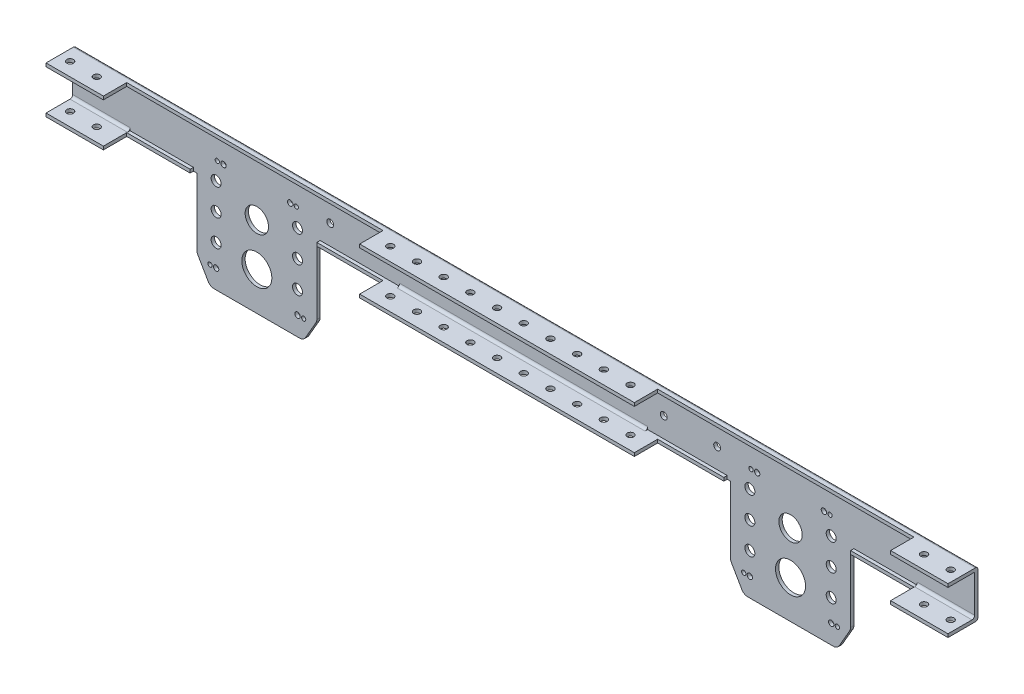
from build123d import *
from build123d.topology import SkipClean

# Parameters (mm, degrees)
SKETCH1_R            = 6.35
BOSS_EXTRUDE1_DEPTH  = 3.175
SKETCH2_W            = 596.9
SKETCH2_H            = 3.175
BOSS_EXTRUDE2_DEPTH  = 25.4
FILLET1_R            = 2.54
SKETCH3_R            = 3.2639
CUT_EXTRUDE1_DEPTH   = 25.4
SKETCH5_R            = 3.2639
CUT_EXTRUDE2_DEPTH   = 25.4
SKETCH6_W            = 31.75
SKETCH6_H            = 44.45
BOSS_EXTRUDE3_DEPTH  = 3.175
SKETCH7_W            = 31.75
SKETCH7_H            = 3.175
SKETCH7_W_2          = 381
BOSS_EXTRUDE4_DEPTH  = 25.4
FILLET2_R            = 2.54
SKETCH8_R            = 3.2639
CUT_EXTRUDE3_DEPTH   = 177.8
SKETCH9_R            = 3.2639
CUT_EXTRUDE5_DEPTH   = 432.308
BOSS_EXTRUDE6_DEPTH  = 66.675
BOSS_EXTRUDE7_START  = 66.675
BOSS_EXTRUDE7_DEPTH  = 66.675
SKETCH12_R           = 6.35
SKETCH12_R_2         = 3.2639
SKETCH12_W           = 256.6289
SKETCH12_H           = 252.715944366
CUT_EXTRUDE8_DEPTH   = 66.675
BOSS_EXTRUDE8_START  = 19.05
BOSS_EXTRUDE8_DEPTH  = 19.05
BOSS_EXTRUDE9_DEPTH  = 19.05
SKETCH16_R           = 3.2639
CUT_EXTRUDE9_DEPTH   = 133.096
SKETCH17_R           = 3.175
CUT_EXTRUDE11_DEPTH  = 5.08
SKETCH18_W           = 256.6289
SKETCH18_H           = 3.175
SKETCH18_W_2         = 838.2
BOSS_EXTRUDE10_DEPTH = 3.175
SKETCH19_W           = 107.950440108
SKETCH19_H           = 6.388661832
SKETCH19_W_2         = 107.95
SKETCH19_H_2         = 3.175
CUT_EXTRUDE12_DEPTH  = 3.175
SKETCH20_W           = 555.272296498
SKETCH20_H           = 244.428342312
SKETCH20_R           = 3.2639
SKETCH20_R_2         = 6.35
SKETCH20_R_3         = 3.175
CUT_EXTRUDE13_DEPTH  = 277.622
BOSS_EXTRUDE11_START = -3.175
SKETCH21_R           = 6.35
BOSS_EXTRUDE11_DEPTH = 3.175
SKETCH22_W           = 47.625
SKETCH22_H           = 22.225
SKETCH22_W_2         = 236.0422
BOSS_EXTRUDE12_DEPTH = 3.175
SKETCH23_W           = 47.625
SKETCH23_H           = 22.225
SKETCH23_W_2         = 236.0422
BOSS_EXTRUDE14_DEPTH = 3.175
BOSS_EXTRUDE15_DEPTH = 12.7
BOSS_EXTRUDE16_START = 12.7
BOSS_EXTRUDE16_DEPTH = 12.7
SKETCH27_R           = 3.175
CUT_EXTRUDE15_DEPTH  = 76.2
SKETCH28_W           = 22.225
SKETCH28_H           = 3.175
BOSS_EXTRUDE17_DEPTH = 12.7
SKETCH29_W           = 22.225
SKETCH29_H           = 3.175
BOSS_EXTRUDE18_DEPTH = 12.7
SKETCH30_R           = 6.35
SKETCH30_R_2         = 5.185373
SKETCH30_R_3         = 5.538595338
BOSS_EXTRUDE19_DEPTH = 3.175
SKETCH31_R           = 14.2875
SKETCH31_R_2         = 11.1125
SKETCH31_R_3         = 4.7625
SKETCH31_R_4         = 2.54
SKETCH31_R_5         = 2.032
CUT_EXTRUDE17_DEPTH  = 3.175
BOSS_EXTRUDE21_DEPTH = 3.175
FILLET4_R            = 6.35
SKETCH34_W           = 94.166192965
SKETCH34_H           = 14.648074461
BOSS_EXTRUDE22_DEPTH = 3.175
SKETCH35_R           = 2.54
SKETCH35_R_2         = 2.032
CUT_EXTRUDE19_DEPTH  = 3.175
SKETCH36_W           = 101.173518356
SKETCH36_H           = 13.169600398
BOSS_EXTRUDE24_DEPTH = 3.175
SKETCH37_W           = 9.525
SKETCH37_H           = 3.175
SKETCH37_W_2         = 3.175
CUT_EXTRUDE20_DEPTH  = 3.175
CUT_EXTRUDE21_START  = -3.175
CUT_EXTRUDE21_DEPTH  = 3.175
CUT_EXTRUDE22_DEPTH  = 3.175
CUT_EXTRUDE23_DEPTH  = 2.54
CUT_EXTRUDE24_START  = -2.54
CUT_EXTRUDE24_DEPTH  = 2.54


with BuildPart() as part:
    # Sketch1 → Boss-Extrude1 (new body)
    with BuildSketch(Plane.XY):
        with BuildLine():
            Line((50.8, 0), (50.8, 25.4))
            ThreePointArc((50.8, 25.4), (52.659871939, 29.890128061), (57.15, 31.75))
            Line((57.15, 31.75), (438.15, 31.75))
            ThreePointArc((438.15, 31.75), (442.640128061, 29.890128061), (444.5, 25.4))
            Line((444.5, 25.4), (444.5, 0))
            ThreePointArc((444.5, 0), (495.3, -50.8), (546.1, 0))
            Line((546.1, 0), (546.1, 76.2))
            Line((546.1, 76.2), (-50.8, 76.2))
            Line((-50.8, 76.2), (-50.8, 0))
            ThreePointArc((-50.8, 0), (0, -50.8), (50.8, 0))
        make_face()
        Circle(SKETCH1_R, mode=Mode.SUBTRACT)
        with Locations((495.3, 0)):
            Circle(SKETCH1_R, mode=Mode.SUBTRACT)
    extrude(amount=BOSS_EXTRUDE1_DEPTH)

    # Sketch2 → Boss-Extrude2 (add)
    with BuildSketch(Plane.XY.offset(3.175)):
        with Locations((247.65, 74.6125)):
            Rectangle(SKETCH2_W, SKETCH2_H)
    extrude(amount=BOSS_EXTRUDE2_DEPTH)

    # Fillet1
    fillet1_edges = [part.edges().sort_by_distance(p)[0] for p in [
        (247.65, 73.025, 3.175),
        (247.65, 76.2, 0),
    ]]
    fillet(fillet1_edges, radius=FILLET1_R)

    # Sketch3 → Cut-Extrude1 (cut)
    with BuildSketch(Plane(origin=(0, 76.2, 0), x_dir=(1, 0, 0), z_dir=(0, 1, 0))):
        with Locations((527.05, -15.5575)):
            Circle(SKETCH3_R)
        with Locations((501.65, -15.5575)):
            Circle(SKETCH3_R)
        with Locations((476.25, -15.5575)):
            Circle(SKETCH3_R)
        with Locations((450.85, -15.5575)):
            Circle(SKETCH3_R)
        with Locations((425.45, -15.5575)):
            Circle(SKETCH3_R)
        with Locations((400.05, -15.5575)):
            Circle(SKETCH3_R)
        with Locations((374.65, -15.5575)):
            Circle(SKETCH3_R)
        with Locations((349.25, -15.5575)):
            Circle(SKETCH3_R)
        with Locations((323.85, -15.5575)):
            Circle(SKETCH3_R)
        with Locations((298.45, -15.5575)):
            Circle(SKETCH3_R)
        with Locations((273.05, -15.5575)):
            Circle(SKETCH3_R)
        with Locations((247.65, -15.5575)):
            Circle(SKETCH3_R)
        with Locations((222.25, -15.5575)):
            Circle(SKETCH3_R)
        with Locations((196.85, -15.5575)):
            Circle(SKETCH3_R)
        with Locations((171.45, -15.5575)):
            Circle(SKETCH3_R)
        with Locations((146.05, -15.5575)):
            Circle(SKETCH3_R)
        with Locations((120.65, -15.5575)):
            Circle(SKETCH3_R)
        with Locations((95.25, -15.5575)):
            Circle(SKETCH3_R)
        with Locations((69.85, -15.5575)):
            Circle(SKETCH3_R)
        with Locations((44.45, -15.5575)):
            Circle(SKETCH3_R)
        with Locations((19.05, -15.5575)):
            Circle(SKETCH3_R)
        with Locations((-6.35, -15.5575)):
            Circle(SKETCH3_R)
        with Locations((-31.75, -15.5575)):
            Circle(SKETCH3_R)
    extrude(amount=-CUT_EXTRUDE1_DEPTH, mode=Mode.SUBTRACT)

    # Sketch5 → Cut-Extrude2 (cut)
    with BuildSketch(Plane(origin=(0, 0, 0), x_dir=(-1, 0, 0), z_dir=(0, 0, -1))):
        with Locations((-425.45, 53.975)):
            Circle(SKETCH5_R)
        with Locations((-374.65, 53.975)):
            Circle(SKETCH5_R)
        with Locations((-323.85, 53.975)):
            Circle(SKETCH5_R)
        with Locations((-273.05, 53.975)):
            Circle(SKETCH5_R)
        with Locations((-222.25, 53.975)):
            Circle(SKETCH5_R)
        with Locations((-171.45, 53.975)):
            Circle(SKETCH5_R)
        with Locations((-120.65, 53.975)):
            Circle(SKETCH5_R)
        with Locations((-69.85, 53.975)):
            Circle(SKETCH5_R)
    extrude(amount=-CUT_EXTRUDE2_DEPTH, mode=Mode.SUBTRACT)

    # Sketch6 → Boss-Extrude3 (add)
    with BuildSketch(Plane.XY.offset(3.175)):
        with Locations((-66.675, 53.975)):
            Rectangle(SKETCH6_W, SKETCH6_H)
        with Locations((561.975, 53.975)):
            Rectangle(SKETCH6_W, SKETCH6_H)
    extrude(amount=-BOSS_EXTRUDE3_DEPTH)

    # Sketch7 → Boss-Extrude4 (add)
    with BuildSketch(Plane.XY.offset(3.175)):
        with Locations((-66.675, 74.6125)):
            Rectangle(SKETCH7_W, SKETCH7_H)
        with Locations((-66.675, 33.3375)):
            Rectangle(SKETCH7_W, SKETCH7_H)
        with Locations((561.975, 74.6125)):
            Rectangle(SKETCH7_W, SKETCH7_H)
        with Locations((561.975, 33.3375)):
            Rectangle(SKETCH7_W, SKETCH7_H)
        with Locations((247.65, 33.3375)):
            Rectangle(SKETCH7_W_2, SKETCH7_H)
    extrude(amount=BOSS_EXTRUDE4_DEPTH)

    # Fillet2
    fillet2_edges = [part.edges().sort_by_distance(p)[0] for p in [
        (-50.8, 15.875, 0),
        (0, -50.8, 0),
        (50.8, 12.7, 0),
        (52.659871939, 29.890128061, 0),
        (546.1, 15.875, 0),
        (495.3, -50.8, 0),
        (444.5, 12.7, 0),
        (442.640128061, 29.890128061, 0),
        (-66.675, 34.925, 3.175),
        (-66.675, 31.75, 0),
        (247.65, 31.75, 0),
        (247.65, 34.925, 3.175),
        (561.975, 34.925, 3.175),
        (561.975, 31.75, 0),
        (561.975, 76.2, 0),
        (-66.675, 76.2, 0),
    ]]
    fillet(fillet2_edges, radius=FILLET2_R)

    # Sketch8 → Cut-Extrude3 (cut)
    with BuildSketch(Plane(origin=(0, 76.2, 0), x_dir=(1, 0, 0), z_dir=(0, 1, 0))):
        with Locations((-31.75, -15.5575)):
            Circle(SKETCH8_R)
        with Locations((-57.15, -15.5575)):
            Circle(SKETCH8_R)
        with Locations((-6.35, -15.5575)):
            Circle(SKETCH8_R)
        with Locations((19.05, -15.5575)):
            Circle(SKETCH8_R)
        with Locations((44.45, -15.5575)):
            Circle(SKETCH8_R)
        with Locations((69.85, -15.5575)):
            Circle(SKETCH8_R)
        with Locations((95.25, -15.5575)):
            Circle(SKETCH8_R)
        with Locations((120.65, -15.5575)):
            Circle(SKETCH8_R)
        with Locations((146.05, -15.5575)):
            Circle(SKETCH8_R)
        with Locations((171.45, -15.5575)):
            Circle(SKETCH8_R)
        with Locations((196.85, -15.5575)):
            Circle(SKETCH8_R)
        with Locations((222.25, -15.5575)):
            Circle(SKETCH8_R)
        with Locations((247.65, -15.5575)):
            Circle(SKETCH8_R)
        with Locations((273.05, -15.5575)):
            Circle(SKETCH8_R)
        with Locations((298.45, -15.5575)):
            Circle(SKETCH8_R)
        with Locations((323.85, -15.5575)):
            Circle(SKETCH8_R)
        with Locations((349.25, -15.5575)):
            Circle(SKETCH8_R)
        with Locations((374.65, -15.5575)):
            Circle(SKETCH8_R)
        with Locations((400.05, -15.5575)):
            Circle(SKETCH8_R)
        with Locations((425.45, -15.5575)):
            Circle(SKETCH8_R)
        with Locations((450.85, -15.5575)):
            Circle(SKETCH8_R)
        with Locations((476.25, -15.5575)):
            Circle(SKETCH8_R)
        with Locations((501.65, -15.5575)):
            Circle(SKETCH8_R)
        with Locations((527.05, -15.5575)):
            Circle(SKETCH8_R)
        with Locations((552.45, -15.5575)):
            Circle(SKETCH8_R)
    extrude(amount=-CUT_EXTRUDE3_DEPTH, mode=Mode.SUBTRACT)

    # Sketch9 → Cut-Extrude5 (cut)
    with BuildSketch(Plane(origin=(0, 76.2, 0), x_dir=(1, 0, 0), z_dir=(0, 1, 0))):
        with BuildLine():
            Line((298.45, -18.8214), (298.45, -28.575))
            Line((298.45, -28.575), (746.392900795, -28.575))
            Line((746.392900795, -28.575), (746.392900795, 89.004110939))
            Line((746.392900795, 89.004110939), (298.45, 89.004110939))
            Line((298.45, 89.004110939), (298.45, -12.2936))
            ThreePointArc((298.45, -12.2936), (301.7139, -15.5575), (298.45, -18.8214))
        make_face()
        with Locations((323.85, -15.5575)):
            Circle(SKETCH9_R, mode=Mode.SUBTRACT)
        with Locations((349.25, -15.5575)):
            Circle(SKETCH9_R, mode=Mode.SUBTRACT)
        with Locations((374.65, -15.5575)):
            Circle(SKETCH9_R, mode=Mode.SUBTRACT)
        with Locations((400.05, -15.5575)):
            Circle(SKETCH9_R, mode=Mode.SUBTRACT)
        with Locations((425.45, -15.5575)):
            Circle(SKETCH9_R, mode=Mode.SUBTRACT)
        with Locations((450.85, -15.5575)):
            Circle(SKETCH9_R, mode=Mode.SUBTRACT)
        with Locations((476.25, -15.5575)):
            Circle(SKETCH9_R, mode=Mode.SUBTRACT)
        with Locations((501.65, -15.5575)):
            Circle(SKETCH9_R, mode=Mode.SUBTRACT)
        with Locations((527.05, -15.5575)):
            Circle(SKETCH9_R, mode=Mode.SUBTRACT)
        with Locations((552.45, -15.5575)):
            Circle(SKETCH9_R, mode=Mode.SUBTRACT)
    extrude(amount=-CUT_EXTRUDE5_DEPTH, mode=Mode.SUBTRACT)

    # Mirror4: part across plane


with BuildPart() as part_1:
    with SkipClean():  # the faces are left unmerged after this step: merging them gives an invalid solid
        add(part.part)
        add(part.part.mirror(Plane(origin=(298.45, -356.108, 0), x_dir=(0, 0, 1), z_dir=(1, 0, 0))))

    # Sketch10 → Boss-Extrude6 (add)
    with SkipClean():  # the faces are left unmerged after this step: merging them gives an invalid solid
        with BuildSketch(Plane.ZY.offset(82.55)):
            with BuildLine():
                Line((0, 73.66), (0, 34.29))
                ThreePointArc((0, 34.29), (0.743948776, 32.493948776), (2.54, 31.75))
                Line((2.54, 31.75), (28.575, 31.75))
                Line((28.575, 31.75), (28.575, 34.925))
                Line((28.575, 34.925), (5.715, 34.925))
                ThreePointArc((5.715, 34.925), (3.918948776, 35.668948776), (3.175, 37.465))
                Line((3.175, 37.465), (3.175, 73.025))
                Line((3.175, 73.025), (28.575, 73.025))
                Line((28.575, 73.025), (28.575, 76.2))
                Line((28.575, 76.2), (2.54, 76.2))
                ThreePointArc((2.54, 76.2), (0.743948776, 75.456051224), (0, 73.66))
            make_face()
        extrude(amount=BOSS_EXTRUDE6_DEPTH)

    # Sketch11 → Boss-Extrude7 (add)
    with SkipClean():  # the faces are left unmerged after this step: merging them gives an invalid solid
        with BuildSketch(Plane(origin=(679.45, 0, 0), x_dir=(0, 0, -1), z_dir=(1, 0, 0)).offset(BOSS_EXTRUDE7_START)):
            with BuildLine():
                Line((0, 34.29), (0, 73.66))
                ThreePointArc((0, 73.66), (-0.743948776, 75.456051224), (-2.54, 76.2))
                Line((-2.54, 76.2), (-28.575, 76.2))
                Line((-28.575, 76.2), (-28.575, 73.025))
                Line((-28.575, 73.025), (-3.175, 73.025))
                Line((-3.175, 73.025), (-3.175, 37.465))
                ThreePointArc((-3.175, 37.465), (-3.918948776, 35.668948776), (-5.715, 34.925))
                Line((-5.715, 34.925), (-28.575, 34.925))
                Line((-28.575, 34.925), (-28.575, 31.75))
                Line((-28.575, 31.75), (-2.54, 31.75))
                ThreePointArc((-2.54, 31.75), (-0.743948776, 32.493948776), (0, 34.29))
            make_face()
        extrude(amount=-BOSS_EXTRUDE7_DEPTH)

    # Sketch12 → Cut-Extrude8 (cut)
    # profile 1 of 2: a face of its own
    with SkipClean():  # the faces are left unmerged after this step: merging them gives an invalid solid
        with BuildSketch(Plane.XY.offset(3.175)):
            with BuildLine():
                Line((135.9789, 114.3), (-120.65, 114.3))
                Line((-120.65, 114.3), (-120.65, -7.986269461))
                Line((-120.65, -7.986269461), (-114.3, -7.986269461))
                Line((-114.3, -7.986269461), (-114.3, 0))
                ThreePointArc((-114.3, 0), (0, -114.3), (114.3, 0))
                Line((114.3, 0), (114.3, -15.458780647))
                Line((114.3, -15.458780647), (135.9789, -15.458780647))
                Line((135.9789, -15.458780647), (135.9789, 114.3))
            make_face()
            Circle(SKETCH12_R, mode=Mode.SUBTRACT)
            with Locations((69.85, 53.975)):
                Circle(SKETCH12_R_2, mode=Mode.SUBTRACT)
            with Locations((120.65, 53.975)):
                Circle(SKETCH12_R_2, mode=Mode.SUBTRACT)
        # profile 2 of 2: a face of its own
        with BuildSketch(Plane.XY.offset(3.175)):
            with Locations((589.23555, 8.748218221)):
                Rectangle(SKETCH12_W, SKETCH12_H)
            with Locations((596.9, 0)):
                Circle(SKETCH12_R, mode=Mode.SUBTRACT)
            with Locations((476.25, 53.975)):
                Circle(SKETCH12_R_2, mode=Mode.SUBTRACT)
            with Locations((527.05, 53.975)):
                Circle(SKETCH12_R_2, mode=Mode.SUBTRACT)
        extrude(amount=CUT_EXTRUDE8_DEPTH, mode=Mode.SUBTRACT)

    # Sketch14 → Boss-Extrude8 (add)
    with SkipClean():  # the faces are left unmerged after this step: merging them gives an invalid solid
        with BuildSketch(Plane(origin=(746.125, 0, 0), x_dir=(0, 0, -1), z_dir=(1, 0, 0)).offset(BOSS_EXTRUDE8_START)):
            with BuildLine():
                Line((0, 34.29), (0, 73.66))
                ThreePointArc((0, 73.66), (-0.743948776, 75.456051224), (-2.54, 76.2))
                Line((-2.54, 76.2), (-28.575, 76.2))
                Line((-28.575, 76.2), (-28.575, 73.025))
                Line((-28.575, 73.025), (-3.175, 73.025))
                Line((-3.175, 73.025), (-3.175, 37.465))
                ThreePointArc((-3.175, 37.465), (-3.918948776, 35.668948776), (-5.715, 34.925))
                Line((-5.715, 34.925), (-28.575, 34.925))
                Line((-28.575, 34.925), (-28.575, 31.75))
                Line((-28.575, 31.75), (-2.54, 31.75))
                ThreePointArc((-2.54, 31.75), (-0.743948776, 32.493948776), (0, 34.29))
            make_face()
        extrude(amount=-BOSS_EXTRUDE8_DEPTH)

    # Sketch15 → Boss-Extrude9 (add)
    with SkipClean():  # the faces are left unmerged after this step: merging them gives an invalid solid
        with BuildSketch(Plane.ZY.offset(149.225)):
            with BuildLine():
                Line((0, 73.66), (0, 34.29))
                ThreePointArc((0, 34.29), (0.743948776, 32.493948776), (2.54, 31.75))
                Line((2.54, 31.75), (28.575, 31.75))
                Line((28.575, 31.75), (28.575, 34.925))
                Line((28.575, 34.925), (5.715, 34.925))
                ThreePointArc((5.715, 34.925), (3.918948776, 35.668948776), (3.175, 37.465))
                Line((3.175, 37.465), (3.175, 73.025))
                Line((3.175, 73.025), (28.575, 73.025))
                Line((28.575, 73.025), (28.575, 76.2))
                Line((28.575, 76.2), (2.54, 76.2))
                ThreePointArc((2.54, 76.2), (0.743948776, 75.456051224), (0, 73.66))
            make_face()
        extrude(amount=BOSS_EXTRUDE9_DEPTH)

    # Sketch16 → Cut-Extrude9 (cut)
    with SkipClean():  # the faces are left unmerged after this step: merging them gives an invalid solid
        with BuildSketch(Plane(origin=(0, 76.2, 0), x_dir=(1, 0, 0), z_dir=(0, 1, 0))):
            with Locations((146.05, -15.5575)):
                Circle(SKETCH16_R)
            with Locations((171.45, -15.5575)):
                Circle(SKETCH16_R)
            with Locations((196.85, -15.5575)):
                Circle(SKETCH16_R)
            with Locations((222.25, -15.5575)):
                Circle(SKETCH16_R)
            with Locations((247.65, -15.5575)):
                Circle(SKETCH16_R)
            with Locations((273.05, -15.5575)):
                Circle(SKETCH16_R)
            with Locations((298.45, -15.5575)):
                Circle(SKETCH16_R)
            with Locations((323.85, -15.5575)):
                Circle(SKETCH16_R)
            with Locations((349.25, -15.5575)):
                Circle(SKETCH16_R)
            with Locations((374.65, -15.5575)):
                Circle(SKETCH16_R)
            with Locations((400.05, -15.5575)):
                Circle(SKETCH16_R)
            with Locations((425.45, -15.5575)):
                Circle(SKETCH16_R)
            with Locations((450.85, -15.5575)):
                Circle(SKETCH16_R)
            with Locations((476.25, -15.5575)):
                Circle(SKETCH16_R)
            with Locations((501.65, -15.5575)):
                Circle(SKETCH16_R)
            with Locations((527.05, -15.5575)):
                Circle(SKETCH16_R)
            with Locations((552.45, -15.5575)):
                Circle(SKETCH16_R)
            with Locations((577.85, -15.5575)):
                Circle(SKETCH16_R)
            with Locations((603.25, -15.5575)):
                Circle(SKETCH16_R)
            with Locations((628.65, -15.5575)):
                Circle(SKETCH16_R)
            with Locations((654.05, -15.5575)):
                Circle(SKETCH16_R)
            with Locations((679.45, -15.5575)):
                Circle(SKETCH16_R)
            with Locations((704.85, -15.5575)):
                Circle(SKETCH16_R)
            with Locations((730.25, -15.5575)):
                Circle(SKETCH16_R)
            with Locations((755.65, -15.5575)):
                Circle(SKETCH16_R)
            with Locations((120.65, -15.5575)):
                Circle(SKETCH16_R)
            with Locations((95.25, -15.5575)):
                Circle(SKETCH16_R)
            with Locations((69.85, -15.5575)):
                Circle(SKETCH16_R)
            with Locations((44.45, -15.5575)):
                Circle(SKETCH16_R)
            with Locations((19.05, -15.5575)):
                Circle(SKETCH16_R)
            with Locations((-6.35, -15.5575)):
                Circle(SKETCH16_R)
            with Locations((-31.75, -15.5575)):
                Circle(SKETCH16_R)
            with Locations((-57.15, -15.5575)):
                Circle(SKETCH16_R)
            with Locations((-82.55, -15.5575)):
                Circle(SKETCH16_R)
            with Locations((-107.95, -15.5575)):
                Circle(SKETCH16_R)
            with Locations((-133.35, -15.5575)):
                Circle(SKETCH16_R)
            with Locations((-158.75, -15.5575)):
                Circle(SKETCH16_R)
        extrude(amount=-CUT_EXTRUDE9_DEPTH, mode=Mode.SUBTRACT)

    # Sketch17 → Cut-Extrude11 (cut)
    with SkipClean():  # the faces are left unmerged after this step: merging them gives an invalid solid
        with BuildSketch(Plane(origin=(0, 0, 0), x_dir=(-1, 0, 0), z_dir=(0, 0, -1))):
            with Locations((0, 63.5)):
                Circle(SKETCH17_R)
            with Locations((-596.9, 63.5)):
                Circle(SKETCH17_R)
        extrude(amount=-CUT_EXTRUDE11_DEPTH, mode=Mode.SUBTRACT)

    # Sketch18 → Boss-Extrude10 (add)
    with SkipClean():  # the faces are left unmerged after this step: merging them gives an invalid solid
        with BuildSketch(Plane.XY.offset(3.175)):
            with Locations((7.66445, 74.6125)):
                Rectangle(SKETCH18_W, SKETCH18_H)
            with Locations((589.23555, 74.6125)):
                Rectangle(SKETCH18_W, SKETCH18_H)
            with Locations((298.45, 33.3375)):
                Rectangle(SKETCH18_W_2, SKETCH18_H)
        extrude(amount=BOSS_EXTRUDE10_DEPTH)

    # Sketch19 → Cut-Extrude12 (cut)
    with SkipClean():  # the faces are left unmerged after this step: merging them gives an invalid solid
        with BuildSketch(Plane.XY.offset(3.175)):
            with Locations((3.175220054, 34.944330916)):
                Rectangle(SKETCH19_W, SKETCH19_H)
            with Locations((593.725, 33.3375)):
                Rectangle(SKETCH19_W_2, SKETCH19_H_2)
        extrude(amount=CUT_EXTRUDE12_DEPTH, mode=Mode.SUBTRACT)

    # Sketch20 → Cut-Extrude13 (cut)
    with BuildSketch(Plane(origin=(0, 0, 0), x_dir=(-1, 0, 0), z_dir=(0, 0, -1))):
        with Locations((-65.263851751, 61.916295681)):
            Rectangle(SKETCH20_W, SKETCH20_H)
        with Locations((-323.85, 53.975)):
            Circle(SKETCH20_R, mode=Mode.SUBTRACT)
        with Locations((-273.05, 53.975)):
            Circle(SKETCH20_R, mode=Mode.SUBTRACT)
        with Locations((-222.25, 53.975)):
            Circle(SKETCH20_R, mode=Mode.SUBTRACT)
        with Locations((-171.45, 53.975)):
            Circle(SKETCH20_R, mode=Mode.SUBTRACT)
        with Locations((-120.65, 53.975)):
            Circle(SKETCH20_R, mode=Mode.SUBTRACT)
        with Locations((-69.85, 53.975)):
            Circle(SKETCH20_R, mode=Mode.SUBTRACT)
        Circle(SKETCH20_R_2, mode=Mode.SUBTRACT)
        with Locations((0, 63.5)):
            Circle(SKETCH20_R_3, mode=Mode.SUBTRACT)
    extrude(amount=-CUT_EXTRUDE13_DEPTH, mode=Mode.SUBTRACT)

    # Sketch21 → Boss-Extrude11 (add)
    with BuildSketch(Plane.XY.offset(3.175).offset(BOSS_EXTRUDE11_START)):
        with BuildLine():
            Line((546.1, 0), (546.1, 25.4))
            ThreePointArc((546.1, 25.4), (544.240128061, 29.890128061), (539.75, 31.75))
            Line((539.75, 31.75), (539.75, 34.925))
            Line((539.75, 34.925), (647.7, 34.925))
            Line((647.7, 34.925), (647.7, 31.75))
            Line((647.7, 31.75), (647.7, 0))
            ThreePointArc((647.7, 0), (596.9, -50.8), (546.1, 0))
        make_face()
        with Locations((596.9, 0)):
            Circle(SKETCH21_R, mode=Mode.SUBTRACT)
    extrude(amount=BOSS_EXTRUDE11_DEPTH)

    # Mirror5: part across plane


with BuildPart() as part_2:
    add(part_1.part)
    add(part_1.part.mirror(Plane(origin=(342.9, 0, 277.622), x_dir=(0, 0, 1), z_dir=(1, 0, 0))))

    # Sketch22 → Boss-Extrude12 (add)
    with BuildSketch(Plane(origin=(0, 76.2, 0), x_dir=(1, 0, 0), z_dir=(0, 1, 0))):
        with Locations((741.3625, -17.4625)):
            Rectangle(SKETCH22_W, SKETCH22_H)
        with Locations((342.9, -17.4625)):
            Rectangle(SKETCH22_W_2, SKETCH22_H)
        with Locations((-55.5625, -17.4625)):
            Rectangle(SKETCH22_W, SKETCH22_H)
    extrude(amount=-BOSS_EXTRUDE12_DEPTH)

    # Sketch23 → Boss-Extrude14 (add)
    with BuildSketch(Plane.XZ.offset(-31.75)):
        with Locations((-55.5625, 17.4625)):
            Rectangle(SKETCH23_W, SKETCH23_H)
        with Locations((342.9, 17.4625)):
            Rectangle(SKETCH23_W_2, SKETCH23_H)
        with Locations((741.3625, 17.4625)):
            Rectangle(SKETCH23_W, SKETCH23_H)
    extrude(amount=-BOSS_EXTRUDE14_DEPTH)

    # Sketch25 → Boss-Extrude15 (add)
    with BuildSketch(Plane.ZY.offset(79.375)):
        with BuildLine():
            Line((2.54, 31.75), (28.575, 31.75))
            Line((28.575, 31.75), (28.575, 34.925))
            Line((28.575, 34.925), (5.715, 34.925))
            ThreePointArc((5.715, 34.925), (3.918948776, 35.668948776), (3.175, 37.465))
            Line((3.175, 37.465), (3.175, 73.025))
            Line((3.175, 73.025), (28.575, 73.025))
            Line((28.575, 73.025), (28.575, 76.2))
            Line((28.575, 76.2), (2.54, 76.2))
            ThreePointArc((2.54, 76.2), (0.743948776, 75.456051224), (0, 73.66))
            Line((0, 73.66), (0, 34.29))
            ThreePointArc((0, 34.29), (0.743948776, 32.493948776), (2.54, 31.75))
        make_face()
    extrude(amount=BOSS_EXTRUDE15_DEPTH)

    # Sketch26 → Boss-Extrude16 (add)
    with BuildSketch(Plane(origin=(765.175, 0, 0), x_dir=(0, 0, -1), z_dir=(1, 0, 0)).offset(BOSS_EXTRUDE16_START)):
        with BuildLine():
            Line((-5.715, 34.925), (-28.575, 34.925))
            Line((-28.575, 34.925), (-28.575, 31.75))
            Line((-28.575, 31.75), (-2.54, 31.75))
            ThreePointArc((-2.54, 31.75), (-0.743948776, 32.493948776), (0, 34.29))
            Line((0, 34.29), (0, 73.66))
            ThreePointArc((0, 73.66), (-0.743948776, 75.456051224), (-2.54, 76.2))
            Line((-2.54, 76.2), (-28.575, 76.2))
            Line((-28.575, 76.2), (-28.575, 73.025))
            Line((-28.575, 73.025), (-3.175, 73.025))
            Line((-3.175, 73.025), (-3.175, 37.465))
            ThreePointArc((-3.175, 37.465), (-3.918948776, 35.668948776), (-5.715, 34.925))
        make_face()
    extrude(amount=-BOSS_EXTRUDE16_DEPTH)

    # Sketch27 → Cut-Extrude15 (cut)
    with BuildSketch(Plane(origin=(0, 76.2, 0), x_dir=(1, 0, 0), z_dir=(0, 1, 0))):
        with Locations((762, -15.788044632)):
            Circle(SKETCH27_R)
        with Locations((736.6, -15.788044632)):
            Circle(SKETCH27_R)
        with Locations((711.2, -15.788044632)):
            Circle(SKETCH27_R)
        with Locations((685.8, -15.788044632)):
            Circle(SKETCH27_R)
        with Locations((660.4, -15.788044632)):
            Circle(SKETCH27_R)
        with Locations((635, -15.788044632)):
            Circle(SKETCH27_R)
        with Locations((609.6, -15.788044632)):
            Circle(SKETCH27_R)
        with Locations((584.2, -15.788044632)):
            Circle(SKETCH27_R)
        with Locations((558.8, -15.788044632)):
            Circle(SKETCH27_R)
        with Locations((533.4, -15.788044632)):
            Circle(SKETCH27_R)
        with Locations((508, -15.788044632)):
            Circle(SKETCH27_R)
        with Locations((482.6, -15.788044632)):
            Circle(SKETCH27_R)
        with Locations((457.2, -15.788044632)):
            Circle(SKETCH27_R)
        with Locations((431.8, -15.788044632)):
            Circle(SKETCH27_R)
        with Locations((406.4, -15.788044632)):
            Circle(SKETCH27_R)
        with Locations((381, -15.788044632)):
            Circle(SKETCH27_R)
        with Locations((355.6, -15.788044632)):
            Circle(SKETCH27_R)
        with Locations((330.2, -15.788044632)):
            Circle(SKETCH27_R)
        with Locations((304.8, -15.788044632)):
            Circle(SKETCH27_R)
        with Locations((279.4, -15.788044632)):
            Circle(SKETCH27_R)
        with Locations((254, -15.788044632)):
            Circle(SKETCH27_R)
        with Locations((228.6, -15.788044632)):
            Circle(SKETCH27_R)
        with Locations((203.2, -15.788044632)):
            Circle(SKETCH27_R)
        with Locations((177.8, -15.788044632)):
            Circle(SKETCH27_R)
        with Locations((152.4, -15.788044632)):
            Circle(SKETCH27_R)
        with Locations((127, -15.788044632)):
            Circle(SKETCH27_R)
        with Locations((101.6, -15.788044632)):
            Circle(SKETCH27_R)
        with Locations((76.2, -15.788044632)):
            Circle(SKETCH27_R)
        with Locations((50.8, -15.788044632)):
            Circle(SKETCH27_R)
        with Locations((25.4, -15.788044632)):
            Circle(SKETCH27_R)
        with Locations((0, -15.788044632)):
            Circle(SKETCH27_R)
        with Locations((-25.4, -15.788044632)):
            Circle(SKETCH27_R)
        with Locations((-50.8, -15.788044632)):
            Circle(SKETCH27_R)
        with Locations((-76.2, -15.788044632)):
            Circle(SKETCH27_R)
    extrude(amount=-CUT_EXTRUDE15_DEPTH, mode=Mode.SUBTRACT)

    # Sketch28 → Boss-Extrude17 (add)
    with BuildSketch(Plane.ZY.offset(-224.8789)):
        with Locations((17.4625, 74.6125)):
            Rectangle(SKETCH28_W, SKETCH28_H)
        with Locations((17.4625, 33.3375)):
            Rectangle(SKETCH28_W, SKETCH28_H)
    extrude(amount=BOSS_EXTRUDE17_DEPTH)

    # Sketch29 → Boss-Extrude18 (add)
    with BuildSketch(Plane(origin=(460.9211, 0, 0), x_dir=(0, 0, -1), z_dir=(1, 0, 0))):
        with Locations((-17.4625, 74.6125)):
            Rectangle(SKETCH29_W, SKETCH29_H)
        with Locations((-17.4625, 33.3375)):
            Rectangle(SKETCH29_W, SKETCH29_H)
    extrude(amount=BOSS_EXTRUDE18_DEPTH)

    # Sketch30 → Boss-Extrude19 (add)
    with BuildSketch(Plane(origin=(0, 0, 0), x_dir=(-1, 0, 0), z_dir=(0, 0, -1))):
        with Locations((-88.9, 0)):
            Circle(SKETCH30_R)
        with Locations((-596.9, 0)):
            Circle(SKETCH30_R)
        with Locations((-596.9, 63.862726265)):
            Circle(SKETCH30_R_2)
        with Locations((-88.9, 63.5)):
            Circle(SKETCH30_R_3)
    extrude(amount=-BOSS_EXTRUDE19_DEPTH)

    # Sketch31 → Cut-Extrude17 (cut)
    with BuildSketch(Plane(origin=(0, 0, 0), x_dir=(-1, 0, 0), z_dir=(0, 0, -1))):
        with Locations((-596.9, -19.05)):
            Circle(SKETCH31_R)
        with Locations((-596.9, 21.6408)):
            Circle(SKETCH31_R_2)
        with Locations((-558.17570279, 9.144)):
            Circle(SKETCH31_R_3)
        with Locations((-558.17570279, 34.544)):
            Circle(SKETCH31_R_3)
        with Locations((-558.17570279, -16.256)):
            Circle(SKETCH31_R_3)
        with Locations((-565.15, 57.205147634)):
            Circle(SKETCH31_R_4)
        with Locations((-559.308, 57.205147634)):
            Circle(SKETCH31_R_5)
        with Locations((-635.62429721, -16.256)):
            Circle(SKETCH31_R_3)
        with Locations((-635.62429721, 9.144)):
            Circle(SKETCH31_R_3)
        with Locations((-634.492, 57.205147634)):
            Circle(SKETCH31_R_5)
        with Locations((-628.65, 57.205147634)):
            Circle(SKETCH31_R_4)
        with Locations((-635.62429721, 34.544)):
            Circle(SKETCH31_R_3)
        with Locations((-50.17570279, -16.256)):
            Circle(SKETCH31_R_3)
        with Locations((-50.17570279, 9.144)):
            Circle(SKETCH31_R_3)
        with Locations((-50.17570279, 34.544)):
            Circle(SKETCH31_R_3)
        with Locations((-51.308, 57.205147634)):
            Circle(SKETCH31_R_5)
        with Locations((-57.15, 57.205147634)):
            Circle(SKETCH31_R_4)
        with Locations((-88.9, 21.6408)):
            Circle(SKETCH31_R_2)
        with Locations((-126.492, 57.205147634)):
            Circle(SKETCH31_R_5)
        with Locations((-120.65, 57.205147634)):
            Circle(SKETCH31_R_4)
        with Locations((-127.62429721, 34.544)):
            Circle(SKETCH31_R_3)
        with Locations((-127.62429721, 9.144)):
            Circle(SKETCH31_R_3)
        with Locations((-127.62429721, -16.256)):
            Circle(SKETCH31_R_3)
        with Locations((-88.9, -19.05)):
            Circle(SKETCH31_R)
    extrude(amount=-CUT_EXTRUDE17_DEPTH, mode=Mode.SUBTRACT)

    # Sketch33 → Boss-Extrude21 (add)
    with BuildSketch(Plane(origin=(0, 0, 0), x_dir=(-1, 0, 0), z_dir=(0, 0, -1))):
        with BuildLine():
            Line((-654.05, -33.374954744), (-641.35, -55.372))
            Line((-641.35, -55.372), (-552.45, -55.372))
            Line((-552.45, -55.372), (-539.75, -33.374954744))
            Line((-539.75, -33.374954744), (-539.75, 31.75))
            ThreePointArc((-539.75, 31.75), (-544.240128061, 29.890128061), (-546.1, 25.4))
            Line((-546.1, 25.4), (-546.1, 0))
            ThreePointArc((-546.1, 0), (-596.9, -50.8), (-647.7, 0))
            Line((-647.7, 0), (-647.7, 34.29))
            Line((-647.7, 34.29), (-654.05, 34.29))
            Line((-654.05, 34.29), (-654.05, -33.374954744))
        make_face()
        with BuildLine():
            Line((-139.7, 0), (-139.7, 25.4))
            ThreePointArc((-139.7, 25.4), (-141.559871939, 29.890128061), (-146.05, 31.75))
            Line((-146.05, 31.75), (-146.05, -33.374954744))
            Line((-146.05, -33.374954744), (-133.35, -55.372))
            Line((-133.35, -55.372), (-44.45, -55.372))
            Line((-44.45, -55.372), (-31.75, -33.374954744))
            Line((-31.75, -33.374954744), (-31.75, 34.29))
            Line((-31.75, 34.29), (-38.1, 34.29))
            Line((-38.1, 34.29), (-38.1, 0))
            ThreePointArc((-38.1, 0), (-88.9, -50.8), (-139.7, 0))
        make_face()
    extrude(amount=-BOSS_EXTRUDE21_DEPTH)

    # Fillet4
    fillet4_edges = [part_2.edges().sort_by_distance(p)[0] for p in [
        (146.05, -33.374954744, 1.5875),
        (133.35, -55.372, 1.5875),
        (44.45, -55.372, 1.5875),
        (31.75, -33.374954744, 1.5875),
        (539.75, -33.374954744, 1.5875),
        (552.45, -55.372, 1.5875),
        (641.35, -55.372, 1.5875),
        (654.05, -33.374954744, 1.5875),
    ]]
    fillet(fillet4_edges, radius=FILLET4_R)

    # Sketch34 → Boss-Extrude22 (add)
    with BuildSketch(Plane.XY.offset(3.175)):
        with Locations((84.981170213, 57.98826549)):
            Rectangle(SKETCH34_W, SKETCH34_H)
    extrude(amount=-BOSS_EXTRUDE22_DEPTH)

    # Sketch35 → Cut-Extrude19 (cut)
    with BuildSketch(Plane.XY.offset(3.175)):
        with Locations((120.65, 51.53152)):
            Circle(SKETCH35_R)
        with Locations((126.492, 51.53152)):
            Circle(SKETCH35_R_2)
        with Locations((127.62429721, -37.36086)):
            Circle(SKETCH35_R)
        with Locations((133.46629721, -37.36086)):
            Circle(SKETCH35_R_2)
        with Locations((44.33370279, -37.36086)):
            Circle(SKETCH35_R_2)
        with Locations((50.17570279, -37.36086)):
            Circle(SKETCH35_R)
        with Locations((51.308, 51.53152)):
            Circle(SKETCH35_R_2)
        with Locations((57.15, 51.53152)):
            Circle(SKETCH35_R)
        with Locations((628.65, 51.53152)):
            Circle(SKETCH35_R)
        with Locations((634.492, 51.53152)):
            Circle(SKETCH35_R_2)
        with Locations((635.62429721, -37.36086)):
            Circle(SKETCH35_R)
        with Locations((641.46629721, -37.36086)):
            Circle(SKETCH35_R_2)
        with Locations((552.33370279, -37.36086)):
            Circle(SKETCH35_R_2)
        with Locations((558.17570279, -37.36086)):
            Circle(SKETCH35_R)
        with Locations((559.308, 51.53152)):
            Circle(SKETCH35_R_2)
        with Locations((565.15, 51.53152)):
            Circle(SKETCH35_R)
    extrude(amount=-CUT_EXTRUDE19_DEPTH, mode=Mode.SUBTRACT)

    # Sketch36 → Boss-Extrude24 (add)
    with BuildSketch(Plane.XY.offset(3.175)):
        with Locations((602.956965064, 61.018078597)):
            Rectangle(SKETCH36_W, SKETCH36_H)
    extrude(amount=-BOSS_EXTRUDE24_DEPTH)

    # Sketch37 → Cut-Extrude20 (cut)
    with BuildSketch(Plane.XY.offset(3.175)):
        with Locations((33.3375, 33.3375)):
            Rectangle(SKETCH37_W, SKETCH37_H)
        with Locations((147.6375, 33.3375)):
            Rectangle(SKETCH37_W_2, SKETCH37_H)
        with Locations((652.4625, 33.3375)):
            Rectangle(SKETCH37_W, SKETCH37_H)
        with Locations((538.1625, 33.3375)):
            Rectangle(SKETCH37_W_2, SKETCH37_H)
    extrude(amount=CUT_EXTRUDE20_DEPTH, mode=Mode.SUBTRACT)

    # Sketch38 → Cut-Extrude21 (cut)
    with BuildSketch(Plane.ZY.offset(92.075).offset(CUT_EXTRUDE21_START)):
        with BuildLine():
            Line((2.54, 31.75), (28.575, 31.75))
            Line((28.575, 31.75), (28.575, 34.925))
            Line((28.575, 34.925), (5.715, 34.925))
            ThreePointArc((5.715, 34.925), (3.918948776, 35.668948776), (3.175, 37.465))
            Line((3.175, 37.465), (3.175, 73.025))
            Line((3.175, 73.025), (28.575, 73.025))
            Line((28.575, 73.025), (28.575, 76.2))
            Line((28.575, 76.2), (2.54, 76.2))
            ThreePointArc((2.54, 76.2), (0.743948776, 75.456051224), (0, 73.66))
            Line((0, 73.66), (0, 34.29))
            ThreePointArc((0, 34.29), (0.743948776, 32.493948776), (2.54, 31.75))
        make_face()
    extrude(amount=CUT_EXTRUDE21_DEPTH, mode=Mode.SUBTRACT)

    # Sketch39 → Cut-Extrude22 (cut)
    with BuildSketch(Plane(origin=(777.875, 0, 0), x_dir=(0, 0, -1), z_dir=(1, 0, 0))):
        with BuildLine():
            Line((-5.715, 34.925), (-28.575, 34.925))
            Line((-28.575, 34.925), (-28.575, 31.75))
            Line((-28.575, 31.75), (-2.54, 31.75))
            ThreePointArc((-2.54, 31.75), (-0.743948776, 32.493948776), (0, 34.29))
            Line((0, 34.29), (0, 73.66))
            ThreePointArc((0, 73.66), (-0.743948776, 75.456051224), (-2.54, 76.2))
            Line((-2.54, 76.2), (-28.575, 76.2))
            Line((-28.575, 76.2), (-28.575, 73.025))
            Line((-28.575, 73.025), (-3.175, 73.025))
            Line((-3.175, 73.025), (-3.175, 37.465))
            ThreePointArc((-3.175, 37.465), (-3.918948776, 35.668948776), (-5.715, 34.925))
        make_face()
    extrude(amount=-CUT_EXTRUDE22_DEPTH, mode=Mode.SUBTRACT)

    # Sketch40 → Cut-Extrude23 (cut)
    with BuildSketch(Plane(origin=(774.7, 0, 0), x_dir=(0, 0, -1), z_dir=(1, 0, 0))):
        with BuildLine():
            Line((-5.715, 34.925), (-28.575, 34.925))
            Line((-28.575, 34.925), (-28.575, 31.75))
            Line((-28.575, 31.75), (-2.54, 31.75))
            ThreePointArc((-2.54, 31.75), (-0.743948776, 32.493948776), (0, 34.29))
            Line((0, 34.29), (0, 73.66))
            ThreePointArc((0, 73.66), (-0.743948776, 75.456051224), (-2.54, 76.2))
            Line((-2.54, 76.2), (-28.575, 76.2))
            Line((-28.575, 76.2), (-28.575, 73.025))
            Line((-28.575, 73.025), (-3.175, 73.025))
            Line((-3.175, 73.025), (-3.175, 37.465))
            ThreePointArc((-3.175, 37.465), (-3.918948776, 35.668948776), (-5.715, 34.925))
        make_face()
    extrude(amount=-CUT_EXTRUDE23_DEPTH, mode=Mode.SUBTRACT)

    # Sketch41 → Cut-Extrude24 (cut)
    with BuildSketch(Plane.ZY.offset(88.9).offset(CUT_EXTRUDE24_START)):
        with BuildLine():
            Line((2.54, 31.75), (28.575, 31.75))
            Line((28.575, 31.75), (28.575, 34.925))
            Line((28.575, 34.925), (5.715, 34.925))
            ThreePointArc((5.715, 34.925), (3.918948776, 35.668948776), (3.175, 37.465))
            Line((3.175, 37.465), (3.175, 73.025))
            Line((3.175, 73.025), (28.575, 73.025))
            Line((28.575, 73.025), (28.575, 76.2))
            Line((28.575, 76.2), (2.54, 76.2))
            ThreePointArc((2.54, 76.2), (0.743948776, 75.456051224), (0, 73.66))
            Line((0, 73.66), (0, 34.29))
            ThreePointArc((0, 34.29), (0.743948776, 32.493948776), (2.54, 31.75))
        make_face()
    extrude(amount=CUT_EXTRUDE24_DEPTH, mode=Mode.SUBTRACT)


solid = part_2.part
